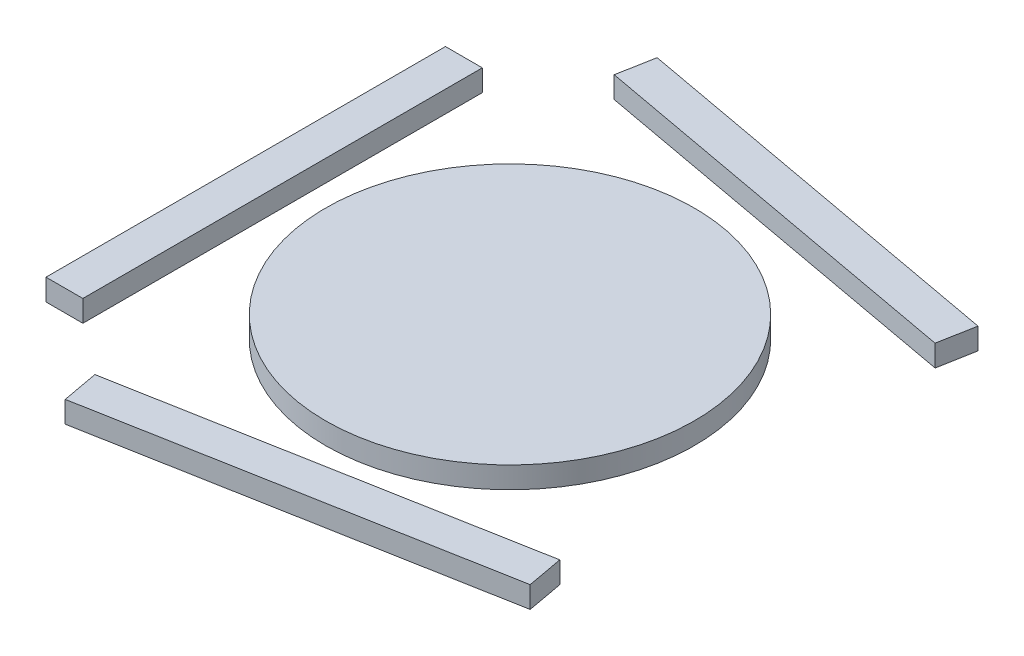
from build123d import *

# Parameters (mm, degrees)
SKETCH1_R             = 300
BOSS_EXTRUDE1_DEPTH   = 35
BOSS_EXTRUDE1_2_DEPTH = 35
SKETCH1_W             = 60
SKETCH1_H             = 650
BOSS_EXTRUDE1_3_DEPTH = 35
BOSS_EXTRUDE1_4_DEPTH = 35


with BuildPart() as part:
    # Sketch1 → Boss-Extrude1 (new body)
    with BuildSketch(Plane(origin=(0, 0, 0), x_dir=(1, 0, 0), z_dir=(0, 1, 0))):
        Circle(SKETCH1_R)
    extrude(amount=BOSS_EXTRUDE1_DEPTH)


with BuildPart() as body_2:
    # Sketch1 → Boss-Extrude1 2 (new body)
    with BuildSketch(Plane(origin=(0, 0, 0), x_dir=(1, 0, 0), z_dir=(0, 1, 0))):
        Polygon((386.393442623, 305.327868852), (-252.950819672, 422.540983607), (-242.131147541, 481.557377049), (397.213114754, 364.344262295), align=None)
    extrude(amount=BOSS_EXTRUDE1_2_DEPTH)


with BuildPart() as body_3:
    # Sketch1 → Boss-Extrude1 3 (new body)
    with BuildSketch(Plane(origin=(0, 0, 0), x_dir=(1, 0, 0), z_dir=(0, 1, 0))):
        with Locations((-400, 0)):
            Rectangle(SKETCH1_W, SKETCH1_H)
    extrude(amount=BOSS_EXTRUDE1_3_DEPTH)


with BuildPart() as body_4:
    # Sketch1 → Boss-Extrude1 4 (new body)
    with BuildSketch(Plane(origin=(0, 0, 0), x_dir=(1, 0, 0), z_dir=(0, 1, 0))):
        Polygon((-242.131147541, -481.557377049), (-252.950819672, -422.540983607), (386.393442623, -305.327868852), (397.213114754, -364.344262295), align=None)
    extrude(amount=BOSS_EXTRUDE1_4_DEPTH)


solid = Compound([part.part, body_2.part, body_3.part, body_4.part])
